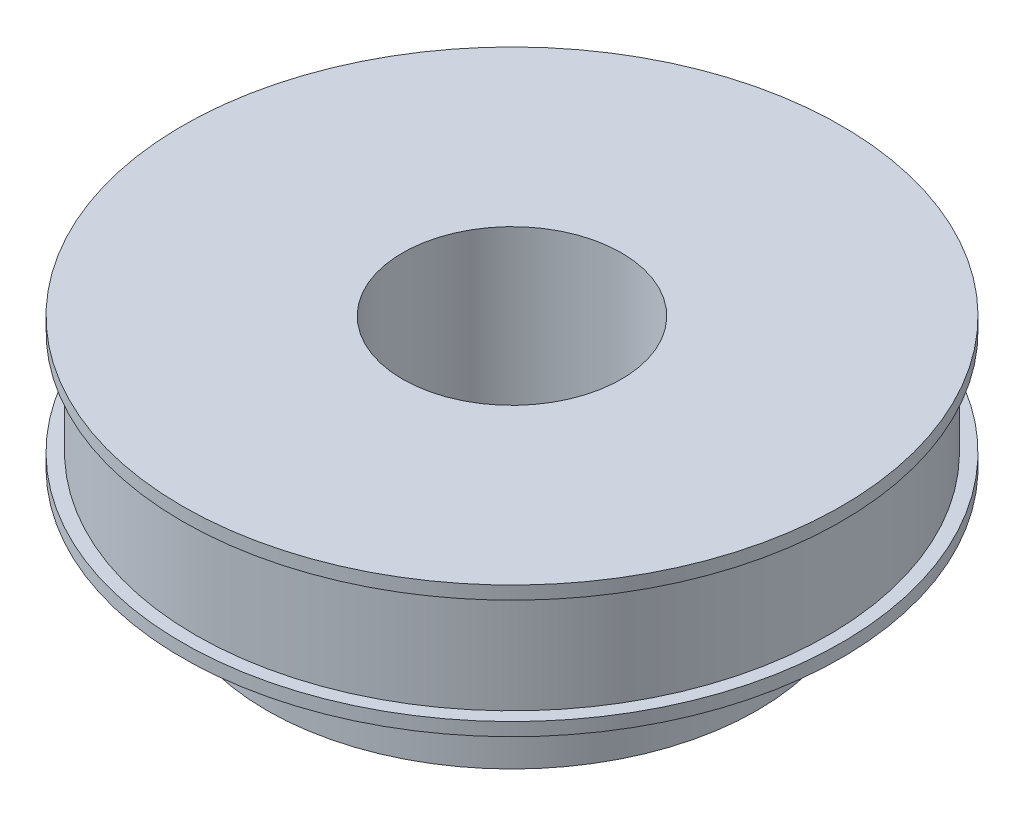
from build123d import *

# Parameters (mm, degrees)
SKETCH1_R           = 36.125
BOSS_EXTRUDE1_DEPTH = 12
SKETCH3_R           = 37.625
BOSS_EXTRUDE3_DEPTH = 1.5
SKETCH4_R           = 37.625
BOSS_EXTRUDE4_DEPTH = 1.5
SKETCH5_R           = 28
BOSS_EXTRUDE5_DEPTH = 10
SKETCH6_R           = 12.5
CUT_EXTRUDE1_DEPTH  = 25


with BuildPart() as part:
    # Sketch1 → Boss-Extrude1 (new body)
    with BuildSketch(Plane(origin=(0, 0, 0), x_dir=(1, 0, 0), z_dir=(0, 1, 0))):
        Circle(SKETCH1_R)
    extrude(amount=BOSS_EXTRUDE1_DEPTH)

    # Sketch3 → Boss-Extrude3 (add)
    with BuildSketch(Plane(origin=(0, 12, 0), x_dir=(1, 0, 0), z_dir=(0, 1, 0))):
        Circle(SKETCH3_R)
    extrude(amount=BOSS_EXTRUDE3_DEPTH)

    # Sketch4 → Boss-Extrude4 (add)
    with BuildSketch(Plane.XZ):
        Circle(SKETCH4_R)
    extrude(amount=BOSS_EXTRUDE4_DEPTH)

    # Sketch5 → Boss-Extrude5 (add)
    with BuildSketch(Plane.XZ.offset(1.5)):
        Circle(SKETCH5_R)
    extrude(amount=BOSS_EXTRUDE5_DEPTH)

    # Sketch6 → Cut-Extrude1 (cut)
    with BuildSketch(Plane(origin=(0, 13.5, 0), x_dir=(1, 0, 0), z_dir=(0, 1, 0))):
        Circle(SKETCH6_R)
    extrude(amount=-CUT_EXTRUDE1_DEPTH, mode=Mode.SUBTRACT)


solid = part.part
